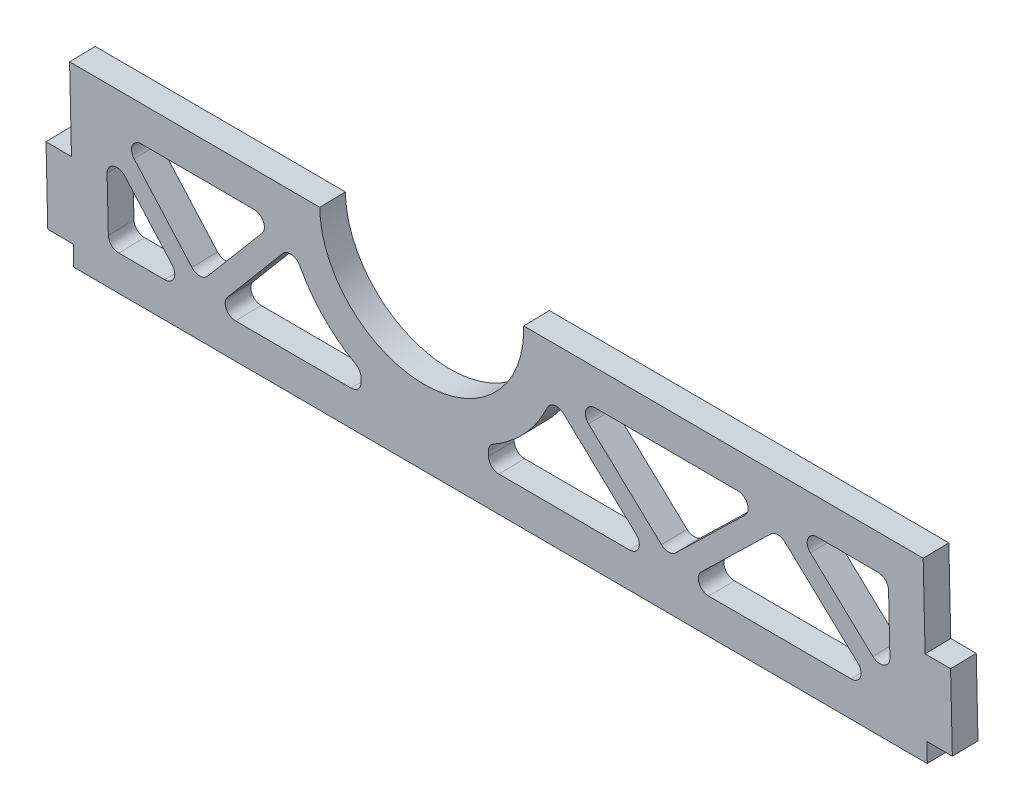
from build123d import *

# Parameters (mm, degrees)
SKETCH1_W           = 6.35
SKETCH1_H           = 19.05
BOSS_EXTRUDE1_DEPTH = 6.35
CUT_EXTRUDE1_DEPTH  = 6.35
EXTRUDE_THIN3_START = -6.35
EXTRUDE_THIN3_DEPTH = 6.35
FILLET2_R           = 2.54


with BuildPart() as part:
    # Sketch1 → Boss-Extrude1 (new body)
    with BuildSketch(Plane(origin=(-0.338050957, -2.166981544, 94.101832391), x_dir=(0.999993551, -8.2681e-05, 0.003590468), z_dir=(-0.00359142, -0.023021797, 0.999728512))):
        with BuildLine():
            Line((243.227078617, -9.06878027), (243.227078617, -28.11878027))
            Line((243.227078617, -28.11878027), (243.227078617, -33.122710711))
            Line((243.227078617, -33.122710711), (455.95107602, -33.122710711))
            Line((455.95107602, -33.122710711), (455.95107602, -28.298303458))
            Line((455.95107602, -28.298303458), (455.951838068, -9.248303458))
            Line((455.951838068, -9.248303458), (455.952670896, 11.571066175))
            Line((455.952670896, 11.571066175), (455.928271144, 11.571065016))
            Line((455.928271144, 11.571065016), (356.413957438, 11.566336687))
            add(Edge.make_bspline(
                [(356.413957438, 11.566336687), (356.413154179, 10.230187882), (356.307050724, 8.928363908), (356.110746239, 7.669666942)],
                knots=[0.928343353, 0.928343353, 0.928343353, 0.928343353, 1, 1, 1, 1], degree=3, weights=[0.866956056, 0.907880921, 0.952228902, 1]))
            Line((356.110746239, 7.669666942), (356.069707191, 7.406526111))
            add(Edge.make_bspline(
                [(356.069707191, 7.406526111), (349.645197224, -33.787190013), (305.128556412, -35.346859606), (305.574396885, 11.563921094)],
                knots=[0, 0, 0, 0, 0.932216201, 0.932216201, 0.932216201, 0.932216201], degree=3, weights=[1, 0.378522533, 0.336396429, 0.873621689]))
            Line((305.574396885, 11.563921094), (243.227078617, 11.56095872))
            Line((243.227078617, 11.56095872), (243.227078617, -9.06878027))
        make_face()
        with Locations((240.052078617, -18.59378027)):
            Rectangle(SKETCH1_W, SKETCH1_H)
        Polygon((455.951838068, -9.248303458), (455.95107602, -28.298303458), (462.301838068, -28.298303458), (462.301838068, -9.248303458), align=None)
    extrude(amount=BOSS_EXTRUDE1_DEPTH)

    # Sketch4 → Cut-Extrude1 (cut)
    with BuildSketch(Plane(origin=(-0.360856472, -2.313169952, 100.450108445), x_dir=(0.999993551, -8.2681e-05, 0.003590468), z_dir=(-0.00359142, -0.023021797, 0.999728512))):
        with BuildLine():
            Line((447.06107602, -24.232710711), (447.061359456, -21.212677023))
            Line((447.061359456, -21.212677023), (447.062315249, 2.680643748))
            Line((447.062315249, 2.680643748), (364.155660196, 2.676704517))
            add(Edge.make_bspline(
                [(364.155660196, 2.676704517), (363.682655748, 0.861202633), (363.064243452, -0.90556276), (361.917066697, -3.482121278), (361.496667699, -4.330871885), (360.585218077, -5.993055638), (360.098114328, -6.79975573), (358.545391798, -9.148799286), (357.388958371, -10.620549815), (355.471920122, -12.686399888), (354.802074961, -13.351532301), (353.400459371, -14.63170826), (352.678029759, -15.238263747), (350.447885909, -16.96045064), (348.877725006, -17.979235773), (347.099980812, -18.935765266), (346.975195928, -19.001918677), (346.849935868, -19.067335155)],
                knots=[0, 0, 0, 0, 0.0625, 0.0625, 0.09375, 0.09375, 0.125, 0.125, 0.1875, 0.1875, 0.21875, 0.21875, 0.25, 0.25, 0.3125, 0.3125, 0.317199008, 0.317199008, 0.317199008, 0.317199008], degree=3))
            Line((346.849935868, -19.067335155), (346.849935868, -24.232710711))
            Line((346.849935868, -24.232710711), (447.06107602, -24.232710711))
        make_face()
        with BuildLine():
            Line((252.117078617, -24.232710711), (315.099935868, -24.232710711))
            Line((315.099935868, -24.232710711), (315.099935868, -19.067335155))
            add(Edge.make_bspline(
                [(315.099935868, -19.067335155), (314.975929033, -19.002569071), (314.852285143, -18.937030581), (313.903603629, -18.426757245), (313.094537504, -17.948032357), (311.509855263, -16.919395321), (310.733380771, -16.36830218), (308.497317264, -14.638176011), (307.115550753, -13.373897611), (305.203441753, -11.314112149), (304.592963657, -10.600151869), (303.426963523, -9.116307482), (302.869814737, -8.343419981), (301.312262481, -5.982806196), (300.415072454, -4.342556455), (298.894695177, -0.932977765), (298.271468298, 0.836332514), (297.792394207, 2.673551329)],
                knots=[0.682832517, 0.682832517, 0.682832517, 0.682832517, 0.6875, 0.6875, 0.71875, 0.71875, 0.75, 0.75, 0.8125, 0.8125, 0.84375, 0.84375, 0.875, 0.875, 0.9375, 0.9375, 1, 1, 1, 1], degree=3))
            Line((297.792394207, 2.673551329), (252.117078617, 2.67138111))
            Line((252.117078617, 2.67138111), (252.117078617, -24.232710711))
        make_face()
    extrude(amount=-CUT_EXTRUDE1_DEPTH, mode=Mode.SUBTRACT)

    # Sketch5 → Extrude-Thin3 (add)
    with BuildSketch(Plane(origin=(-0.360856472, -2.313169952, 100.450108445), x_dir=(0.999993551, -8.2681e-05, 0.003590468), z_dir=(-0.00359142, -0.023021797, 0.999728512)).offset(EXTRUDE_THIN3_START)):
        Polygon((250.180703918, 1.027588841), (274.956201281, -28.157757229), (299.728925104, 1.029943078), (295.85586331, 4.317159581), (274.955828291, -20.307664192), (254.053453316, 4.31517338), align=None)
        Polygon((362.38371865, 0.856862997), (391.792672106, -27.778018594), (419.426789837, -0.86614126), (445.288961546, -26.052383839), (448.833190494, -22.413037583), (419.426789837, 6.224802604), (391.792335202, -20.687402828), (365.927601742, 4.496546037), align=None)
    extrude(amount=EXTRUDE_THIN3_DEPTH)

    # Fillet2
    fillet2_edges = [part.edges().sort_by_distance(p)[0] for p in [
        (298.32854124, -2.470729974, 98.343628252),
        (255.097636261, 0.409634721, 98.254654941),
        (294.109382675, 0.408262278, 98.394768941),
        (251.765998957, -3.514034664, 98.152331935),
        (271.273016149, -26.488822109, 97.693344331),
        (274.60460134, -22.565091347, 97.795668563),
        (277.936290782, -26.489373041, 97.717268759),
        (362.969132405, -2.325780207, 98.579180702),
        (443.068140014, -26.503026473, 98.310173185),
        (395.081122323, -26.49905881, 98.137876228),
        (446.709043574, -22.959091678, 98.404862651),
        (367.44463473, 0.405682327, 98.658158726),
        (415.433854418, 0.403994055, 98.830516083),
        (391.440354753, -22.95438955, 98.206423967),
        (422.715052674, 0.4037379, 98.856667125),
        (419.074631168, -3.140666269, 98.761968583),
        (387.79956879, -26.498456757, 98.111731875),
        (314.748450021, -21.32841022, 97.968359479),
        (314.748450021, -26.492416744, 97.849442487),
        (251.765998957, -26.487209229, 97.623304561),
        (446.709978354, 0.402893753, 98.942846938),
        (346.49824526, -26.495041881, 97.963439843),
        (346.49824526, -21.331035356, 98.082356835),
    ]]
    fillet(fillet2_edges, radius=FILLET2_R)


solid = part.part
